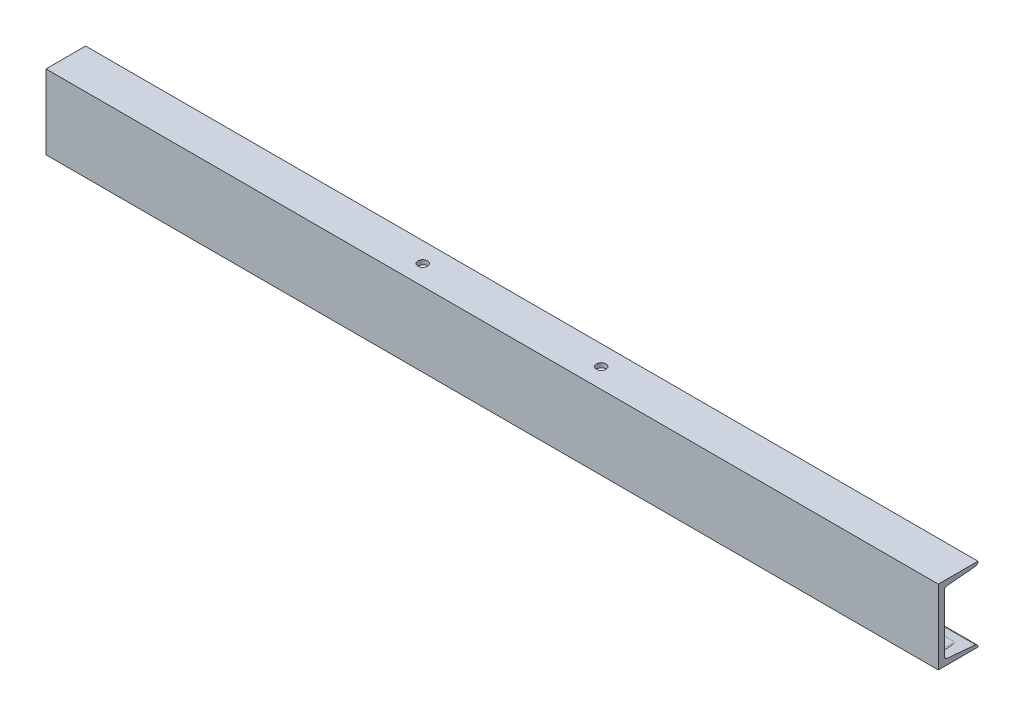
from build123d import *

# Parameters (mm, degrees)
STRUCTURAL_MEMBER1_DEPTH = 900
SKETCH12_R               = 4.7625
CUT_EXTRUDE1_DEPTH       = 454.327971782
CUT_EXTRUDE2_DEPTH       = 40
SKETCH18_R               = 4.7625
CUT_EXTRUDE3_DEPTH       = 10


with BuildPart() as part:
    # Sketch17 → Structural Member1 (new body)
    with BuildSketch(Plane(origin=(-450, 0, 0), x_dir=(0, 0, 1), z_dir=(1, 0, 0))):
        with BuildLine():
            Line((0, 37.5), (0, -37.5))
            Line((0, -37.5), (-40, -37.5))
            Line((-40, -37.5), (-40, -37.246949676))
            ThreePointArc((-40, -37.246949676), (-39.212582687, -35.220998578), (-37.263681431, -34.258560126))
            Line((-37.263681431, -34.258560126), (-8.736318569, -31.741439874))
            ThreePointArc((-8.736318569, -31.741439874), (-6.787417313, -30.779001422), (-6, -28.753050324))
            Line((-6, -28.753050324), (-6, 28.753050324))
            ThreePointArc((-6, 28.753050324), (-6.787417313, 30.779001422), (-8.736318569, 31.741439874))
            Line((-8.736318569, 31.741439874), (-37.263681431, 34.258560126))
            ThreePointArc((-37.263681431, 34.258560126), (-39.212582687, 35.220998578), (-40, 37.246949676))
            Line((-40, 37.246949676), (-40, 37.5))
            Line((-40, 37.5), (0, 37.5))
        make_face()
    extrude(amount=STRUCTURAL_MEMBER1_DEPTH)

    # Sketch12 → Cut-Extrude1 (cut, through all)
    with BuildSketch(Plane(origin=(0, 0, 0), x_dir=(1, 0, 0), z_dir=(0, 1, 0))):
        with Locations(Location((-425, 20, 0), (0, 0, 270))):
            Circle(SKETCH12_R)
        with Locations(Location((425, 20, 0), (0, 0, 270))):
            Circle(SKETCH12_R)
    extrude(amount=-CUT_EXTRUDE1_DEPTH, mode=Mode.SUBTRACT)

    # Sketch15 → Cut-Extrude2 (cut)
    with BuildSketch(Plane(origin=(0, 0, -6), x_dir=(-1, 0, 0), z_dir=(0, 0, -1))):
        with BuildLine():
            Line((-412.5, -33.5), (-437.5, -33.5))
            ThreePointArc((-437.5, -33.5), (-442.5, -28.5), (-437.5, -23.5))
            Line((-437.5, -23.5), (-412.5, -23.5))
            ThreePointArc((-412.5, -23.5), (-407.5, -28.5), (-412.5, -33.5))
        make_face()
        with BuildLine():
            Line((412.5, -33.5), (437.5, -33.5))
            ThreePointArc((437.5, -33.5), (442.5, -28.5), (437.5, -23.5))
            Line((437.5, -23.5), (412.5, -23.5))
            ThreePointArc((412.5, -23.5), (407.5, -28.5), (412.5, -33.5))
        make_face()
    extrude(amount=CUT_EXTRUDE2_DEPTH, mode=Mode.SUBTRACT)

    # Sketch18 → Cut-Extrude3 (cut)
    with BuildSketch(Plane(origin=(0, 37.5, 0), x_dir=(1, 0, 0), z_dir=(0, 1, 0))):
        with Locations(Location((90, 20, 0), (0, 0, 270))):
            Circle(SKETCH18_R)
        with Locations(Location((-90, 20, 0), (0, 0, 270))):
            Circle(SKETCH18_R)
    extrude(amount=-CUT_EXTRUDE3_DEPTH, mode=Mode.SUBTRACT)


solid = part.part
